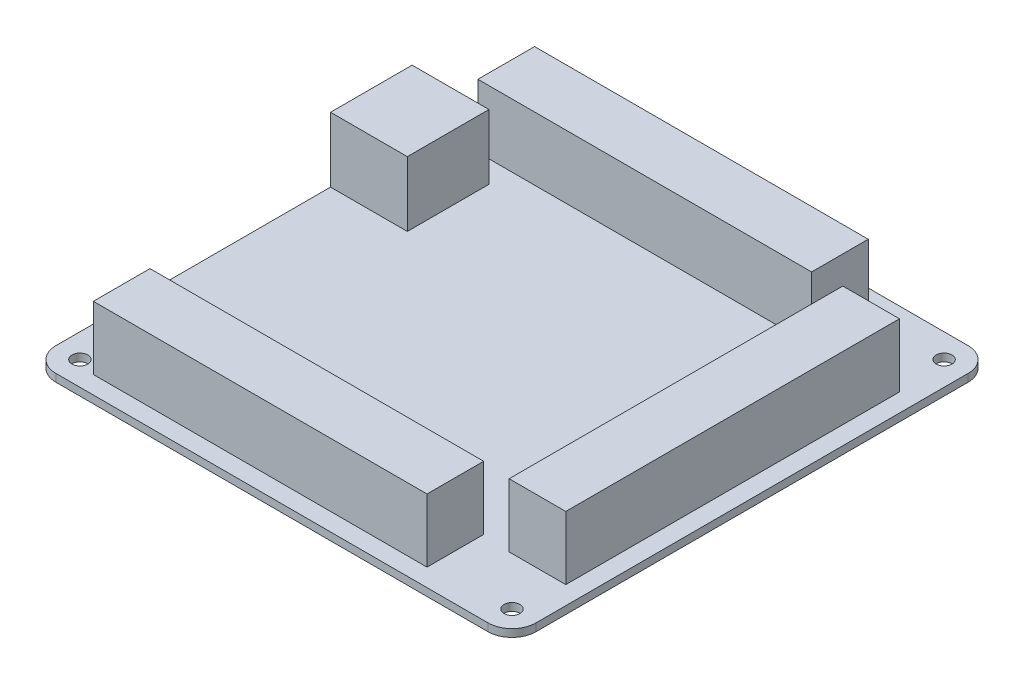
from build123d import *

# Parameters (mm, degrees)
SKETCH1_W                  = 100
SKETCH1_H                  = 100
BOSS_EXTRUDE1_DEPTH        = 1.6
FILLET1_R                  = 5
F_3_3_3_3_DIAMETER_HOLE1_D = 3.3
SKETCH4_W                  = 16
SKETCH4_H                  = 17
BOSS_EXTRUDE2_DEPTH        = 13.5
SKETCH5_W                  = 69.5
SKETCH5_H                  = 11.8
SKETCH5_W_2                = 11.8
SKETCH5_H_2                = 69.5
BOSS_EXTRUDE3_DEPTH        = 13.2


with BuildPart() as part:
    # Sketch1 → Boss-Extrude1 (new body)
    with BuildSketch(Plane(origin=(0, 0, 0), x_dir=(1, 0, 0), z_dir=(0, 1, 0))):
        Rectangle(SKETCH1_W, SKETCH1_H)
    extrude(amount=BOSS_EXTRUDE1_DEPTH)

    # Fillet1
    fillet1_edges = [part.edges().sort_by_distance(p)[0] for p in [
        (50, 0.8, 50),
        (-50, 0.8, 50),
        (-50, 0.8, -50),
        (50, 0.8, -50),
    ]]
    fillet(fillet1_edges, radius=FILLET1_R)

    # Ø3.3 (3.3) Diameter Hole1 (through all)
    with Locations(Plane(origin=(0, 1.6, 0), x_dir=(1, 0, 0), z_dir=(0, 1, 0))):
        with Locations((45, -45), (-45, -45), (-45, 45), (45, 45)):
            Hole(F_3_3_3_3_DIAMETER_HOLE1_D / 2)

    # Sketch4 → Boss-Extrude2 (add)
    with BuildSketch(Plane(origin=(0, 1.6, 0), x_dir=(1, 0, 0), z_dir=(0, 1, 0))):
        with Locations((-42, 20.7)):
            Rectangle(SKETCH4_W, SKETCH4_H)
    extrude(amount=BOSS_EXTRUDE2_DEPTH)

    # Sketch5 → Boss-Extrude3 (add)
    with BuildSketch(Plane(origin=(0, 1.6, 0), x_dir=(1, 0, 0), z_dir=(0, 1, 0))):
        with Locations((-6.15, 39.7)):
            Rectangle(SKETCH5_W, SKETCH5_H)
        with Locations((40.3, -0.25)):
            Rectangle(SKETCH5_W_2, SKETCH5_H_2)
        with Locations((-6.15, -40.4)):
            Rectangle(SKETCH5_W, SKETCH5_H)
    extrude(amount=BOSS_EXTRUDE3_DEPTH)


solid = part.part
